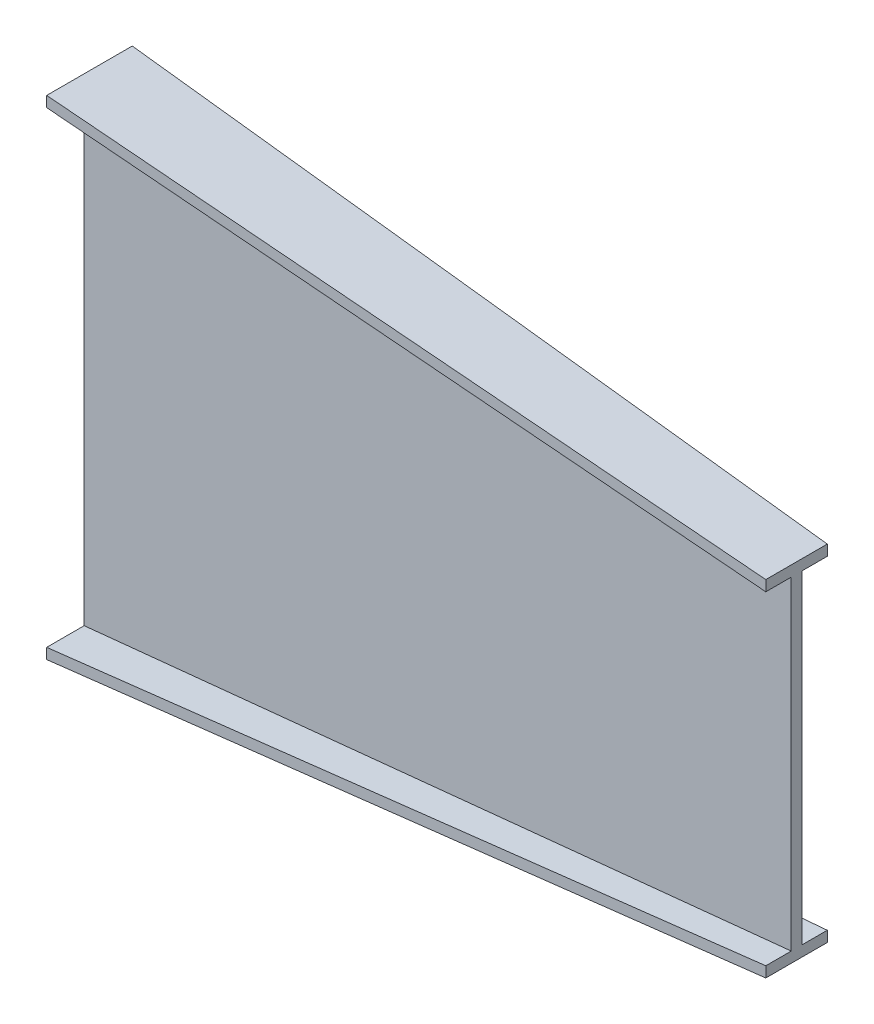
from build123d import *


with BuildPart() as part:
    # Sketch1 → Loft l3 section 0
    with BuildSketch(Plane(origin=(0, 0, 0), x_dir=(0, 0, -1), z_dir=(1, 0, 0))):
        Polygon((-68, 345.5), (53, 345.5), (53, 330.5), (0, 330.5), (0, -330.5), (53, -330.5), (53, -345.5), (-68, -345.5), (-68, -330.5), (-15, -330.5), (-15, 330.5), (-68, 330.5), align=None)
    # Sketch4 → Loft l3 section 1
    with BuildSketch(Plane(origin=(1000, 0, -1000), x_dir=(0, 0, 1), z_dir=(-1, 0, 0))):
        Polygon((964, 244), (1051, 244), (1051, 229), (1015, 229), (1015, -229), (1051, -229), (1051, -244), (964, -244), (964, -229), (1000, -229), (1000, 229), (964, 229), align=None)
    loft()


solid = part.part
